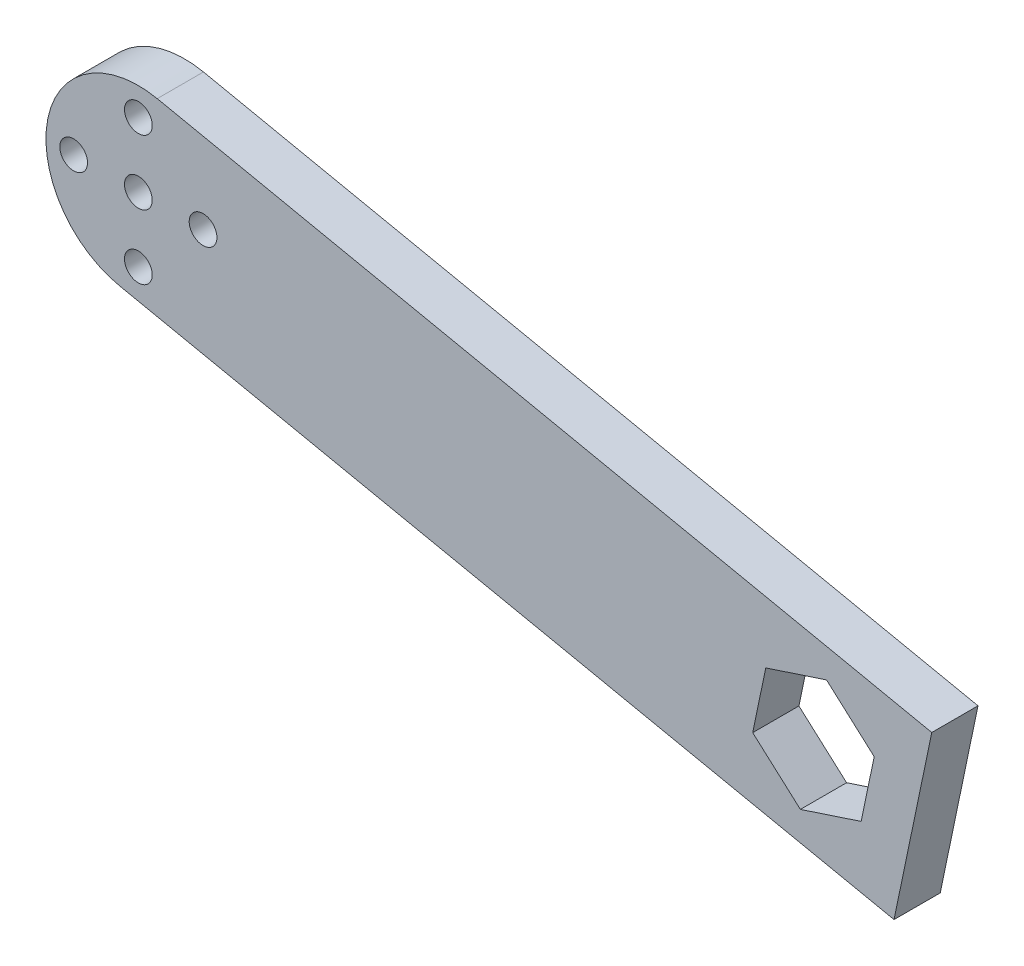
from build123d import *

# Parameters (mm, degrees)
SKETCH2_R           = 1.5
BOSS_EXTRUDE1_DEPTH = 5


with BuildPart() as part:
    # Sketch2 → Boss-Extrude1 (new body)
    with BuildSketch(Plane.XY):
        with BuildLine():
            Line((2.043003371, 9.789082553), (85.846562924, -7.700907316))
            Line((85.846562924, -7.700907316), (81.760556182, -27.279072422))
            Line((81.760556182, -27.279072422), (-2.043003371, -9.789082553))
            ThreePointArc((-2.043003371, -9.789082553), (-9.789082553, 2.043003371), (2.043003371, 9.789082553))
        make_face()
        Circle(SKETCH2_R, mode=Mode.SUBTRACT)
        with Locations((0, 7)):
            Circle(SKETCH2_R, mode=Mode.SUBTRACT)
        with Locations((0, -7)):
            Circle(SKETCH2_R, mode=Mode.SUBTRACT)
        with Locations((7, 0)):
            Circle(SKETCH2_R, mode=Mode.SUBTRACT)
        with Locations((-7, 0)):
            Circle(SKETCH2_R, mode=Mode.SUBTRACT)
        Polygon((74.456281443, -8.470092426), (67.882907111, -10.632764358), (66.469148778, -17.406809485), (71.628764778, -22.018182679), (78.20213911, -19.855510747), (79.615897443, -13.08146562), align=None, mode=Mode.SUBTRACT)
    extrude(amount=BOSS_EXTRUDE1_DEPTH)


solid = part.part
